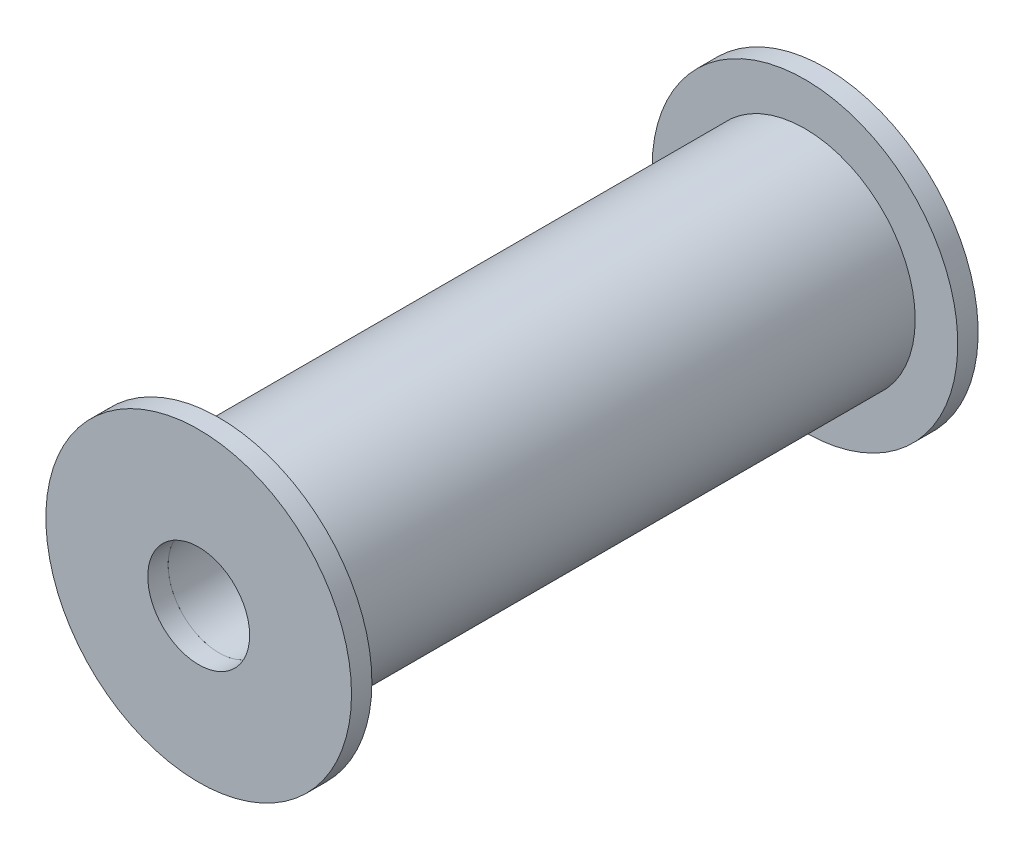
from build123d import *

# Parameters (mm, degrees)
SKETCH1_R           = 21.643869335
SKETCH1_R_2         = 10
BOSS_EXTRUDE1_DEPTH = 115
SKETCH2_R           = 30
SKETCH2_R_2         = 10
BOSS_EXTRUDE2_DEPTH = 4
SKETCH3_R           = 30
SKETCH3_R_2         = 10
BOSS_EXTRUDE3_DEPTH = 4


with BuildPart() as part:
    # Sketch1 → Boss-Extrude1 (new body)
    with BuildSketch(Plane.XY):
        Circle(SKETCH1_R)
        Circle(SKETCH1_R_2, mode=Mode.SUBTRACT)
    extrude(amount=BOSS_EXTRUDE1_DEPTH)

    # Sketch3 → Boss-Extrude3 (add)
    with BuildSketch(Plane(origin=(0, 0, 0), x_dir=(-1, 0, 0), z_dir=(0, 0, -1))):
        Circle(SKETCH3_R)
        Circle(SKETCH3_R_2, mode=Mode.SUBTRACT)
    extrude(amount=BOSS_EXTRUDE3_DEPTH)


with BuildPart() as body_2:
    # Sketch2 → Boss-Extrude2 (new body)
    with BuildSketch(Plane.XY.offset(115)):
        Circle(SKETCH2_R)
        Circle(SKETCH2_R_2, mode=Mode.SUBTRACT)
    extrude(amount=BOSS_EXTRUDE2_DEPTH)


solid = Compound([part.part, body_2.part])
